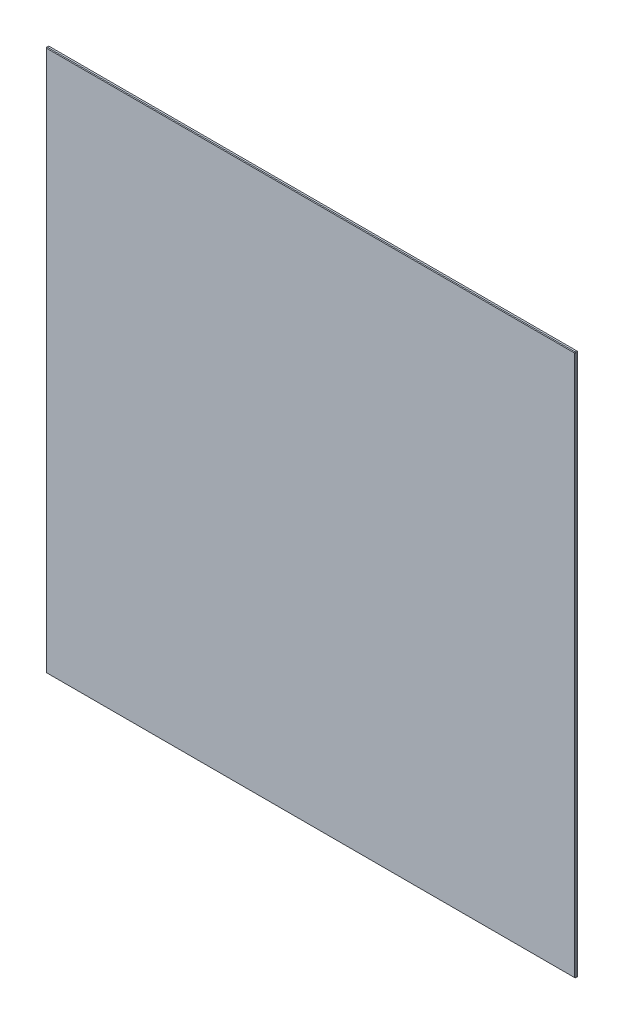
from build123d import *

# Parameters (mm, degrees)
SKETCH1_W           = 420
SKETCH1_H           = 430
BOSS_EXTRUDE1_DEPTH = 2.38125
CHAMFER1_SIZE       = 0.5


with BuildPart() as part:
    # Sketch1 → Boss-Extrude1 (new body)
    with BuildSketch(Plane.XY):
        Rectangle(SKETCH1_W, SKETCH1_H)
    extrude(amount=BOSS_EXTRUDE1_DEPTH)

    # Chamfer1
    chamfer1_edges = [part.edges().sort_by_distance(p)[0] for p in [
        (-210, 0, 2.38125),
        (0, -215, 2.38125),
        (210, 0, 2.38125),
        (0, -215, 0),
        (-210, 0, 0),
        (0, 215, 0),
        (210, 0, 0),
        (0, 215, 2.38125),
        (210, -215, 1.190625),
        (-210, -215, 1.190625),
        (-210, 215, 1.190625),
        (210, 215, 1.190625),
    ]]
    chamfer(chamfer1_edges, length=CHAMFER1_SIZE)


solid = part.part
